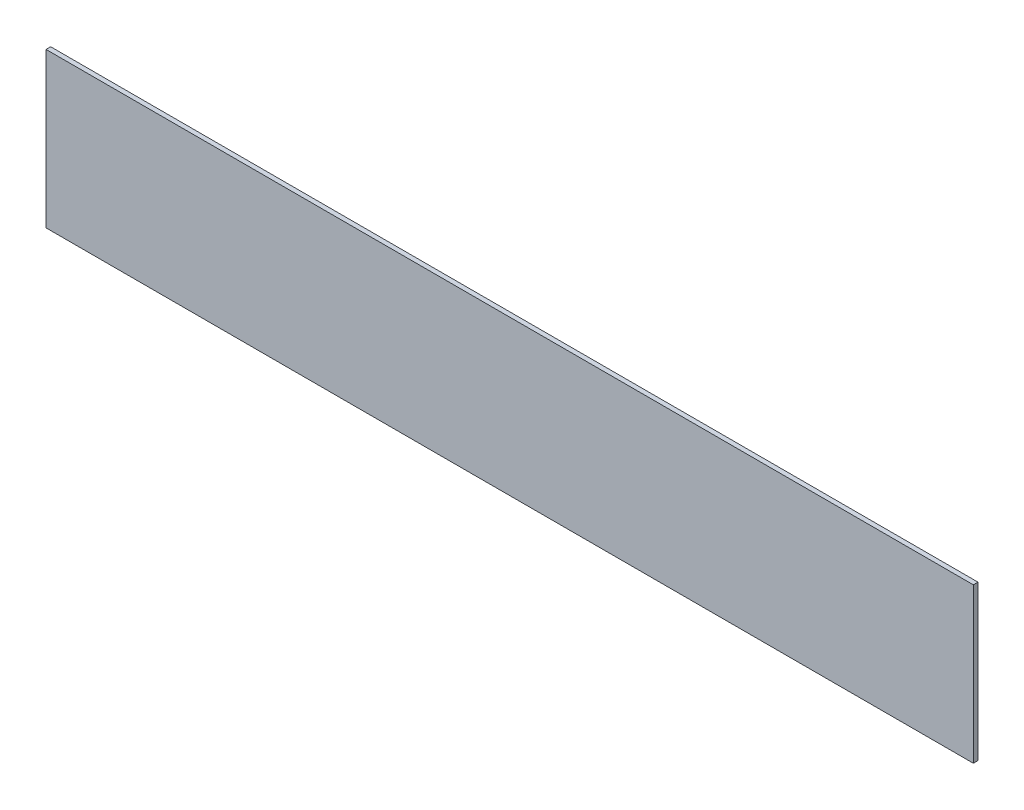
from build123d import *

# Parameters (mm, degrees)
SKETCH2_W           = 600
SKETCH2_H           = 100
BOSS_EXTRUDE1_DEPTH = 3


with BuildPart() as part:
    # Sketch2 → Boss-Extrude1 (new body)
    with BuildSketch(Plane.XY):
        with Locations((300, 50)):
            Rectangle(SKETCH2_W, SKETCH2_H)
    extrude(amount=BOSS_EXTRUDE1_DEPTH)


solid = part.part
